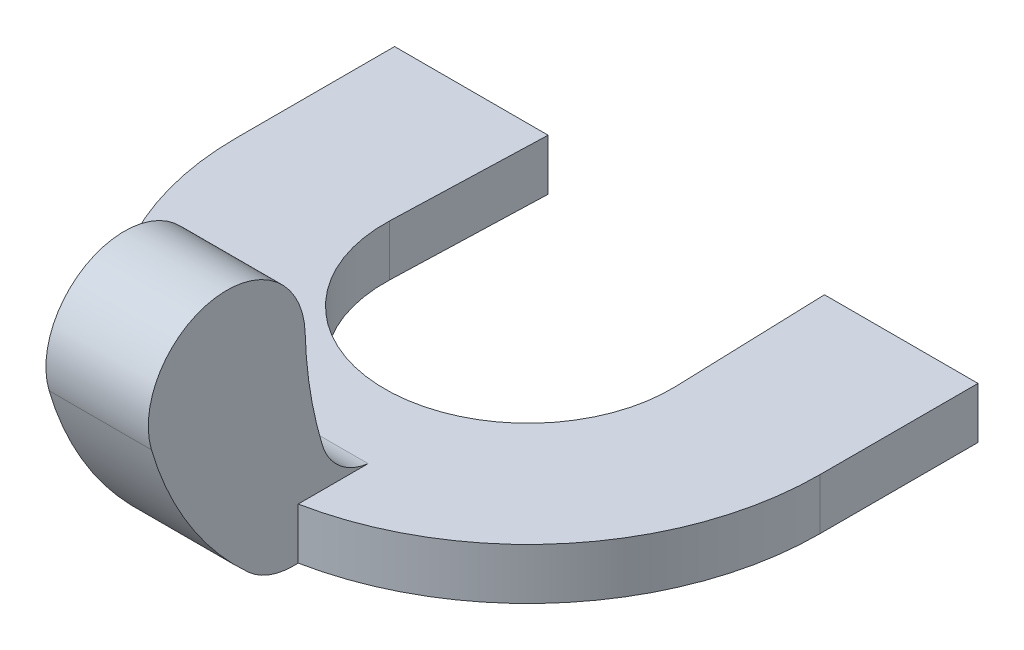
from build123d import *

# Parameters (mm, degrees)
BOSS_EXTRUDE1_DEPTH      = 1
BOSS_EXTRUDE2_START      = 2.8
BOSS_EXTRUDE2_DEPTH      = 1
BOSS_EXTRUDE2_DEPTH_BACK = 1


with BuildPart() as part:
    # Sketch1 → Boss-Extrude1 (new body)
    with BuildSketch(Plane(origin=(0, 0, 0), x_dir=(1, 0, 0), z_dir=(0, 1, 0))):
        with BuildLine():
            Line((0, 0), (-3, 0))
            Line((-3, 0), (-3, -3.090307428))
            ThreePointArc((-3, -3.090307428), (2.7, -8.790307428), (8.4, -3.090307428))
            Line((8.4, -3.090307428), (8.4, 0))
            Line((8.4, 0), (5.4, 0))
            Line((5.4, 0), (5.498490641, -2.99838283))
            ThreePointArc((5.498490641, -2.99838283), (2.7, -5.890307428), (-0.098490641, -2.99838283))
            Line((-0.098490641, -2.99838283), (0, 0))
        make_face()
    extrude(amount=BOSS_EXTRUDE1_DEPTH)

    # Sketch2 → Boss-Extrude2 (add, two sides)
    with BuildSketch(Plane(origin=(0, 0, 0), x_dir=(0, 0, -1), z_dir=(1, 0, 0)).offset(BOSS_EXTRUDE2_START)) as boss_extrude2_sk:
        with BuildLine():
            Line((-6.335210042, 0), (-8.790307428, 0))
            ThreePointArc((-8.790307428, 0), (-9.254427116, 0.08633492), (-9.656455715, 0.333789578))
            ThreePointArc((-9.656455715, 0.333789578), (-10.811745574, 1.711404626), (-11.550251819, 3.350650307))
            ThreePointArc((-11.550251819, 3.350650307), (-10.32088682, 5.296716398), (-8.547723139, 3.828928236))
            ThreePointArc((-8.547723139, 3.828928236), (-8.447124365, 2.781446668), (-8.209910935, 1.756230818))
            ThreePointArc((-8.209910935, 1.756230818), (-7.874898379, 1.24587868), (-7.316117214, 1))
            Line((-7.316117214, 1), (-6.335210042, 1))
            Line((-6.335210042, 1), (-6.335210042, 0))
        make_face()
    extrude(amount=BOSS_EXTRUDE2_DEPTH)
    extrude(boss_extrude2_sk.sketch, amount=-BOSS_EXTRUDE2_DEPTH_BACK)


solid = part.part
